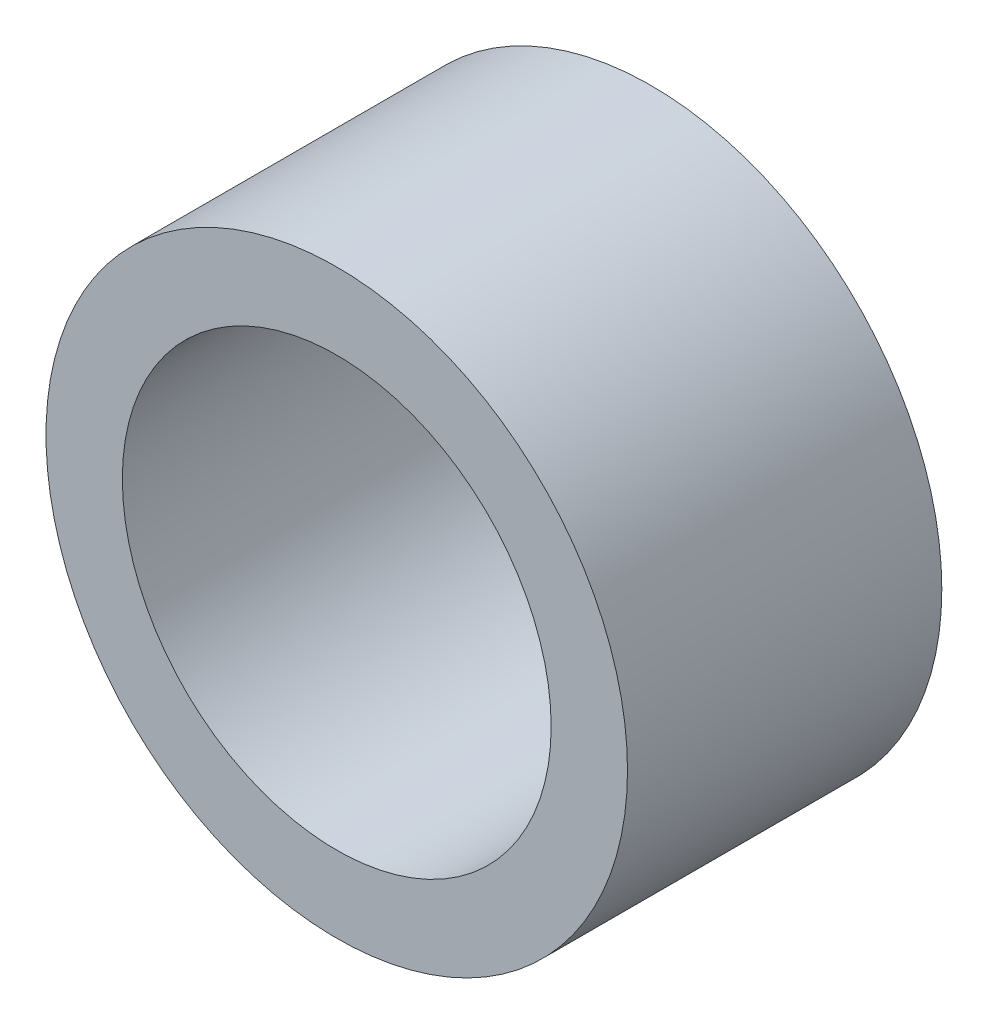
from build123d import *

# Parameters (mm, degrees)
SKETCH1_R           = 6.5786
SKETCH1_R_2         = 4.8514
BOSS_EXTRUDE1_DEPTH = 7.112


with BuildPart() as part:
    # Sketch1 → Boss-Extrude1 (new body)
    with BuildSketch(Plane.XY):
        Circle(SKETCH1_R)
        Circle(SKETCH1_R_2, mode=Mode.SUBTRACT)
    extrude(amount=BOSS_EXTRUDE1_DEPTH)


solid = part.part
